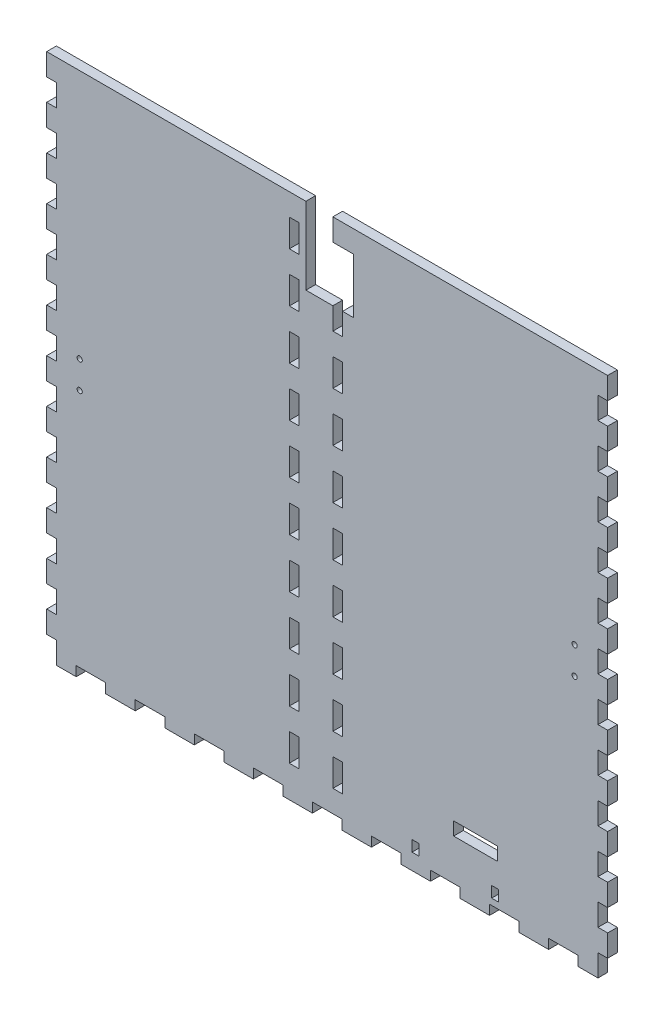
from build123d import *

# Parameters (mm, degrees)
SKETCH1_W                = 323.85
SKETCH1_H                = 139.7
BOSS_EXTRUDE1_DEPTH      = 5.588
SKETCH2_W                = 323.85
SKETCH2_H                = 139.7
SKETCH2_W_2              = 312.674
SKETCH2_H_2              = 128.524
BOSS_EXTRUDE2_DEPTH      = 298.45
SKETCH3_W                = 6.35
SKETCH3_H                = 16.933333333
SKETCH3_H_2              = 16.933333334
DOOR_SLOT_DEPTH          = 12.7
DOOR_GUIDE_HOLES_REACH   = 371.655
SKETCH4_W                = 5.588
SKETCH4_H                = 15.875
LEVER_HOLES_R            = 1.5
LEVER_HOLES_W            = 25.4
LEVER_HOLES_H            = 7.62
LEVER_HOLES_W_2          = 3.999992
LEVER_HOLES_H_2          = 6.35
LEVERHOLE_CUT_DEPTH      = 372.718846804
CUT_EXTRUDE2_REACH       = 451.663
SKETCH7_R                = 26.9875
CUT_EXTRUDE3_REACH       = 451.663
SKETCH8_R                = 3.175
SKETCH15_W               = 152.451001563
SKETCH15_H               = 327.672221774
CUT_EXTRUDE8_DEPTH       = 450.663152197
FRONT_BACK_W             = 5.588
FRONT_BACK_H             = 12.66825
FRONT_BACK_W_2           = 17.044736842
FRONT_BACK_H_2           = 5.588
CUT_EXTRUDE9_DEPTH       = 372.718846804
SKETCH16_W               = 11.938
SKETCH16_H               = 31.75
SKETCH16_W_2             = 15.5800044
SKETCH16_H_2             = 12.7
CUT_EXTRUDE10_DEPTH      = 345.51420408
CUT_EXTRUDE10_DEPTH_BACK = 345.51420408


with BuildPart() as part:
    # Sketch1 → Boss-Extrude1 (new body)
    with BuildSketch(Plane(origin=(0, 0, 0), x_dir=(1, 0, 0), z_dir=(0, 1, 0))):
        Rectangle(SKETCH1_W, SKETCH1_H)
    extrude(amount=BOSS_EXTRUDE1_DEPTH)

    # Sketch2 → Boss-Extrude2 (add)
    with BuildSketch(Plane(origin=(0, 5.588, 0), x_dir=(1, 0, 0), z_dir=(0, 1, 0))):
        Rectangle(SKETCH2_W, SKETCH2_H)
        Rectangle(SKETCH2_W_2, SKETCH2_H_2, mode=Mode.SUBTRACT)
    extrude(amount=BOSS_EXTRUDE2_DEPTH)

    # Sketch3 → Door Slot (cut)
    with BuildSketch(Plane.XY.offset(69.85)):
        with BuildLine():
            Line((-3.302, 282.448), (-3.302, 5.588))
            Line((-3.302, 5.588), (3.302, 5.588))
            Line((3.302, 5.588), (3.302, 291.592))
            Line((3.302, 291.592), (-16.256, 291.592))
            Line((-16.256, 291.592), (-16.256, 284.988))
            Line((-16.256, 284.988), (-5.842, 284.988))
            ThreePointArc((-5.842, 284.988), (-4.045948776, 284.244051224), (-3.302, 282.448))
        make_face()
        with Locations((12.827, 80.433333334)):
            Rectangle(SKETCH3_W, SKETCH3_H)
        with Locations((12.827, 50.8)):
            Rectangle(SKETCH3_W, SKETCH3_H_2)
        with Locations((12.827, 21.166666667)):
            Rectangle(SKETCH3_W, SKETCH3_H)
    extrude(amount=-DOOR_SLOT_DEPTH, mode=Mode.SUBTRACT)

    # Sketch4 → Door Guide Holes (cut, up to next)
    with BuildSketch(Plane.XY.offset(-64.262), mode=Mode.PRIVATE) as door_guide_holes_sk1:
        with Locations((-19.05, 283.4005)):
            Rectangle(SKETCH4_W, SKETCH4_H)
    door_guide_holes_tool1 = extrude(door_guide_holes_sk1.sketch, amount=-DOOR_GUIDE_HOLES_REACH, mode=Mode.PRIVATE) & part.part
    # Sketch4 → Door Guide Holes (cut, up to next)
    with BuildSketch(Plane.XY.offset(-64.262), mode=Mode.PRIVATE) as door_guide_holes_sk2:
        with Locations((-19.05, 254.8255)):
            Rectangle(SKETCH4_W, SKETCH4_H)
    door_guide_holes_tool2 = extrude(door_guide_holes_sk2.sketch, amount=-DOOR_GUIDE_HOLES_REACH, mode=Mode.PRIVATE) & part.part
    # Sketch4 → Door Guide Holes (cut, up to next)
    with BuildSketch(Plane.XY.offset(-64.262), mode=Mode.PRIVATE) as door_guide_holes_sk3:
        with Locations((-19.05, 226.2505)):
            Rectangle(SKETCH4_W, SKETCH4_H)
    door_guide_holes_tool3 = extrude(door_guide_holes_sk3.sketch, amount=-DOOR_GUIDE_HOLES_REACH, mode=Mode.PRIVATE) & part.part
    # Sketch4 → Door Guide Holes (cut, up to next)
    with BuildSketch(Plane.XY.offset(-64.262), mode=Mode.PRIVATE) as door_guide_holes_sk4:
        with Locations((-19.05, 197.6755)):
            Rectangle(SKETCH4_W, SKETCH4_H)
    door_guide_holes_tool4 = extrude(door_guide_holes_sk4.sketch, amount=-DOOR_GUIDE_HOLES_REACH, mode=Mode.PRIVATE) & part.part
    # Sketch4 → Door Guide Holes (cut, up to next)
    with BuildSketch(Plane.XY.offset(-64.262), mode=Mode.PRIVATE) as door_guide_holes_sk5:
        with Locations((-19.05, 169.1005)):
            Rectangle(SKETCH4_W, SKETCH4_H)
    door_guide_holes_tool5 = extrude(door_guide_holes_sk5.sketch, amount=-DOOR_GUIDE_HOLES_REACH, mode=Mode.PRIVATE) & part.part
    # Sketch4 → Door Guide Holes (cut, up to next)
    with BuildSketch(Plane.XY.offset(-64.262), mode=Mode.PRIVATE) as door_guide_holes_sk6:
        with Locations((-19.05, 140.5255)):
            Rectangle(SKETCH4_W, SKETCH4_H)
    door_guide_holes_tool6 = extrude(door_guide_holes_sk6.sketch, amount=-DOOR_GUIDE_HOLES_REACH, mode=Mode.PRIVATE) & part.part
    # Sketch4 → Door Guide Holes (cut, up to next)
    with BuildSketch(Plane.XY.offset(-64.262), mode=Mode.PRIVATE) as door_guide_holes_sk7:
        with Locations((-19.05, 111.9505)):
            Rectangle(SKETCH4_W, SKETCH4_H)
    door_guide_holes_tool7 = extrude(door_guide_holes_sk7.sketch, amount=-DOOR_GUIDE_HOLES_REACH, mode=Mode.PRIVATE) & part.part
    # Sketch4 → Door Guide Holes (cut, up to next)
    with BuildSketch(Plane.XY.offset(-64.262), mode=Mode.PRIVATE) as door_guide_holes_sk8:
        with Locations((-19.05, 83.3755)):
            Rectangle(SKETCH4_W, SKETCH4_H)
    door_guide_holes_tool8 = extrude(door_guide_holes_sk8.sketch, amount=-DOOR_GUIDE_HOLES_REACH, mode=Mode.PRIVATE) & part.part
    # Sketch4 → Door Guide Holes (cut, up to next)
    with BuildSketch(Plane.XY.offset(-64.262), mode=Mode.PRIVATE) as door_guide_holes_sk9:
        with Locations((-19.05, 54.8005)):
            Rectangle(SKETCH4_W, SKETCH4_H)
    door_guide_holes_tool9 = extrude(door_guide_holes_sk9.sketch, amount=-DOOR_GUIDE_HOLES_REACH, mode=Mode.PRIVATE) & part.part
    # Sketch4 → Door Guide Holes (cut, up to next)
    with BuildSketch(Plane.XY.offset(-64.262), mode=Mode.PRIVATE) as door_guide_holes_sk10:
        with Locations((-19.05, 26.2255)):
            Rectangle(SKETCH4_W, SKETCH4_H)
    door_guide_holes_tool10 = extrude(door_guide_holes_sk10.sketch, amount=-DOOR_GUIDE_HOLES_REACH, mode=Mode.PRIVATE) & part.part
    door_guide_holes_1 = door_guide_holes_tool1.solids().sort_by_distance((-19.05, 283.4005, -64.262))[0]
    add(door_guide_holes_1, mode=Mode.SUBTRACT)
    door_guide_holes_2 = door_guide_holes_tool2.solids().sort_by_distance((-19.05, 254.8255, -64.262))[0]
    add(door_guide_holes_2, mode=Mode.SUBTRACT)
    door_guide_holes_3 = door_guide_holes_tool3.solids().sort_by_distance((-19.05, 226.2505, -64.262))[0]
    add(door_guide_holes_3, mode=Mode.SUBTRACT)
    door_guide_holes_4 = door_guide_holes_tool4.solids().sort_by_distance((-19.05, 197.6755, -64.262))[0]
    add(door_guide_holes_4, mode=Mode.SUBTRACT)
    door_guide_holes_5 = door_guide_holes_tool5.solids().sort_by_distance((-19.05, 169.1005, -64.262))[0]
    add(door_guide_holes_5, mode=Mode.SUBTRACT)
    door_guide_holes_6 = door_guide_holes_tool6.solids().sort_by_distance((-19.05, 140.5255, -64.262))[0]
    add(door_guide_holes_6, mode=Mode.SUBTRACT)
    door_guide_holes_7 = door_guide_holes_tool7.solids().sort_by_distance((-19.05, 111.9505, -64.262))[0]
    add(door_guide_holes_7, mode=Mode.SUBTRACT)
    door_guide_holes_8 = door_guide_holes_tool8.solids().sort_by_distance((-19.05, 83.3755, -64.262))[0]
    add(door_guide_holes_8, mode=Mode.SUBTRACT)
    door_guide_holes_9 = door_guide_holes_tool9.solids().sort_by_distance((-19.05, 54.8005, -64.262))[0]
    add(door_guide_holes_9, mode=Mode.SUBTRACT)
    door_guide_holes_10 = door_guide_holes_tool10.solids().sort_by_distance((-19.05, 26.2255, -64.262))[0]
    add(door_guide_holes_10, mode=Mode.SUBTRACT)
    door_guide_holes = door_guide_holes_1 + door_guide_holes_2 + door_guide_holes_3 + door_guide_holes_4 + door_guide_holes_5 + door_guide_holes_6 + door_guide_holes_7 + door_guide_holes_8 + door_guide_holes_9 + door_guide_holes_10  # Door Guide Holes as one shape, for the pattern or mirror that repeats it

    # Mirror1: Door Guide Holes across plane
    add(door_guide_holes.mirror(Plane.ZY.offset(6.477)), mode=Mode.SUBTRACT)

    # Lever Holes → LeverHole Cut (cut, through all)
    with BuildSketch(Plane.XY.offset(69.85)):
        with Locations((-142.875, 159.894)):
            Circle(LEVER_HOLES_R)
        with Locations((-142.875, 144.144)):
            Circle(LEVER_HOLES_R)
        with Locations(Location((142.875, 144.144, 0), (0, 0, 180))):
            Circle(LEVER_HOLES_R)
        with Locations(Location((142.875, 159.894, 0), (0, 0, 180))):
            Circle(LEVER_HOLES_R)
        with Locations((85.725, 33.1129894)):
            Rectangle(LEVER_HOLES_W, LEVER_HOLES_H)
        with Locations((50.975012, 12.413)):
            Rectangle(LEVER_HOLES_W_2, LEVER_HOLES_H_2)
        with Locations((96.975004, 12.413)):
            Rectangle(LEVER_HOLES_W_2, LEVER_HOLES_H_2)
    extrude(amount=-LEVERHOLE_CUT_DEPTH, mode=Mode.SUBTRACT)

    # Sketch7 → Cut-Extrude2 (cut, up to next)
    with BuildSketch(Plane(origin=(161.925, 0, 0), x_dir=(0, 0, -1), z_dir=(1, 0, 0)), mode=Mode.PRIVATE) as cut_extrude2_sk1:
        with Locations((0, 55.372)):
            Circle(SKETCH7_R)
    cut_extrude2_tool1 = extrude(cut_extrude2_sk1.sketch, amount=-CUT_EXTRUDE2_REACH, mode=Mode.PRIVATE) & part.part
    # Sketch7 → Cut-Extrude2 (cut, up to next)
    with BuildSketch(Plane(origin=(161.925, 0, 0), x_dir=(0, 0, -1), z_dir=(1, 0, 0)), mode=Mode.PRIVATE) as cut_extrude2_sk2:
        with BuildLine():
            Line((-37.211, 89.408), (-37.211, 92.583))
            Line((-37.211, 92.583), (-34.036, 92.583))
            ThreePointArc((-34.036, 92.583), (-39.45606403, 94.82806403), (-37.211, 89.408))
        make_face()
    cut_extrude2_tool2 = extrude(cut_extrude2_sk2.sketch, amount=-CUT_EXTRUDE2_REACH, mode=Mode.PRIVATE) & part.part
    # Sketch7 → Cut-Extrude2 (cut, up to next)
    with BuildSketch(Plane(origin=(161.925, 0, 0), x_dir=(0, 0, -1), z_dir=(1, 0, 0)), mode=Mode.PRIVATE) as cut_extrude2_sk3:
        with BuildLine():
            Line((-34.036, 92.583), (-37.211, 92.583))
            Line((-37.211, 92.583), (-37.211, 89.408))
            ThreePointArc((-37.211, 89.408), (-34.96593597, 90.33793597), (-34.036, 92.583))
        make_face()
    cut_extrude2_tool3 = extrude(cut_extrude2_sk3.sketch, amount=-CUT_EXTRUDE2_REACH, mode=Mode.PRIVATE) & part.part
    # Sketch7 → Cut-Extrude2 (cut, up to next)
    with BuildSketch(Plane(origin=(161.925, 0, 0), x_dir=(0, 0, -1), z_dir=(1, 0, 0)), mode=Mode.PRIVATE) as cut_extrude2_sk4:
        with BuildLine():
            Line((-37.211, 89.408), (-37.211, 92.583))
            Line((-37.211, 92.583), (-34.036, 92.583))
            ThreePointArc((-34.036, 92.583), (-39.45606403, 94.82806403), (-37.211, 89.408))
        make_face()
    cut_extrude2_tool4 = extrude(cut_extrude2_sk4.sketch, amount=-CUT_EXTRUDE2_REACH, mode=Mode.PRIVATE) & part.part
    # Sketch7 → Cut-Extrude2 (cut, up to next)
    with BuildSketch(Plane(origin=(161.925, 0, 0), x_dir=(0, 0, -1), z_dir=(1, 0, 0)), mode=Mode.PRIVATE) as cut_extrude2_sk5:
        with BuildLine():
            Line((-34.036, 92.583), (-37.211, 92.583))
            Line((-37.211, 92.583), (-37.211, 89.408))
            ThreePointArc((-37.211, 89.408), (-34.96593597, 90.33793597), (-34.036, 92.583))
        make_face()
    cut_extrude2_tool5 = extrude(cut_extrude2_sk5.sketch, amount=-CUT_EXTRUDE2_REACH, mode=Mode.PRIVATE) & part.part
    # Sketch7 → Cut-Extrude2 (cut, up to next)
    with BuildSketch(Plane(origin=(161.925, 0, 0), x_dir=(0, 0, -1), z_dir=(1, 0, 0)), mode=Mode.PRIVATE) as cut_extrude2_sk6:
        with BuildLine():
            ThreePointArc((40.386, 92.583), (37.211, 95.758), (34.036, 92.583))
            Line((34.036, 92.583), (37.211, 92.583))
            Line((37.211, 92.583), (37.211, 89.408))
            ThreePointArc((37.211, 89.408), (39.45606403, 90.33793597), (40.386, 92.583))
        make_face()
    cut_extrude2_tool6 = extrude(cut_extrude2_sk6.sketch, amount=-CUT_EXTRUDE2_REACH, mode=Mode.PRIVATE) & part.part
    # Sketch7 → Cut-Extrude2 (cut, up to next)
    with BuildSketch(Plane(origin=(161.925, 0, 0), x_dir=(0, 0, -1), z_dir=(1, 0, 0)), mode=Mode.PRIVATE) as cut_extrude2_sk7:
        with BuildLine():
            Line((37.211, 92.583), (34.036, 92.583))
            ThreePointArc((34.036, 92.583), (34.96593597, 90.33793597), (37.211, 89.408))
            Line((37.211, 89.408), (37.211, 92.583))
        make_face()
    cut_extrude2_tool7 = extrude(cut_extrude2_sk7.sketch, amount=-CUT_EXTRUDE2_REACH, mode=Mode.PRIVATE) & part.part
    # Sketch7 → Cut-Extrude2 (cut, up to next)
    with BuildSketch(Plane(origin=(161.925, 0, 0), x_dir=(0, 0, -1), z_dir=(1, 0, 0)), mode=Mode.PRIVATE) as cut_extrude2_sk8:
        with BuildLine():
            ThreePointArc((40.386, 92.583), (37.211, 95.758), (34.036, 92.583))
            Line((34.036, 92.583), (37.211, 92.583))
            Line((37.211, 92.583), (37.211, 89.408))
            ThreePointArc((37.211, 89.408), (39.45606403, 90.33793597), (40.386, 92.583))
        make_face()
    cut_extrude2_tool8 = extrude(cut_extrude2_sk8.sketch, amount=-CUT_EXTRUDE2_REACH, mode=Mode.PRIVATE) & part.part
    # Sketch7 → Cut-Extrude2 (cut, up to next)
    with BuildSketch(Plane(origin=(161.925, 0, 0), x_dir=(0, 0, -1), z_dir=(1, 0, 0)), mode=Mode.PRIVATE) as cut_extrude2_sk9:
        with BuildLine():
            Line((37.211, 92.583), (34.036, 92.583))
            ThreePointArc((34.036, 92.583), (34.96593597, 90.33793597), (37.211, 89.408))
            Line((37.211, 89.408), (37.211, 92.583))
        make_face()
    cut_extrude2_tool9 = extrude(cut_extrude2_sk9.sketch, amount=-CUT_EXTRUDE2_REACH, mode=Mode.PRIVATE) & part.part
    # Sketch7 → Cut-Extrude2 (cut, up to next)
    with BuildSketch(Plane(origin=(161.925, 0, 0), x_dir=(0, 0, -1), z_dir=(1, 0, 0)), mode=Mode.PRIVATE) as cut_extrude2_sk10:
        with BuildLine():
            ThreePointArc((-34.036, 18.161), (-34.96593597, 20.40606403), (-37.211, 21.336))
            Line((-37.211, 21.336), (-37.211, 18.161))
            Line((-37.211, 18.161), (-34.036, 18.161))
        make_face()
    cut_extrude2_tool10 = extrude(cut_extrude2_sk10.sketch, amount=-CUT_EXTRUDE2_REACH, mode=Mode.PRIVATE) & part.part
    # Sketch7 → Cut-Extrude2 (cut, up to next)
    with BuildSketch(Plane(origin=(161.925, 0, 0), x_dir=(0, 0, -1), z_dir=(1, 0, 0)), mode=Mode.PRIVATE) as cut_extrude2_sk11:
        with BuildLine():
            Line((-37.211, 18.161), (-37.211, 21.336))
            ThreePointArc((-37.211, 21.336), (-39.45606403, 15.91593597), (-34.036, 18.161))
            Line((-34.036, 18.161), (-37.211, 18.161))
        make_face()
    cut_extrude2_tool11 = extrude(cut_extrude2_sk11.sketch, amount=-CUT_EXTRUDE2_REACH, mode=Mode.PRIVATE) & part.part
    # Sketch7 → Cut-Extrude2 (cut, up to next)
    with BuildSketch(Plane(origin=(161.925, 0, 0), x_dir=(0, 0, -1), z_dir=(1, 0, 0)), mode=Mode.PRIVATE) as cut_extrude2_sk12:
        with BuildLine():
            ThreePointArc((-34.036, 18.161), (-34.96593597, 20.40606403), (-37.211, 21.336))
            Line((-37.211, 21.336), (-37.211, 18.161))
            Line((-37.211, 18.161), (-34.036, 18.161))
        make_face()
    cut_extrude2_tool12 = extrude(cut_extrude2_sk12.sketch, amount=-CUT_EXTRUDE2_REACH, mode=Mode.PRIVATE) & part.part
    # Sketch7 → Cut-Extrude2 (cut, up to next)
    with BuildSketch(Plane(origin=(161.925, 0, 0), x_dir=(0, 0, -1), z_dir=(1, 0, 0)), mode=Mode.PRIVATE) as cut_extrude2_sk13:
        with BuildLine():
            Line((-37.211, 18.161), (-37.211, 21.336))
            ThreePointArc((-37.211, 21.336), (-39.45606403, 15.91593597), (-34.036, 18.161))
            Line((-34.036, 18.161), (-37.211, 18.161))
        make_face()
    cut_extrude2_tool13 = extrude(cut_extrude2_sk13.sketch, amount=-CUT_EXTRUDE2_REACH, mode=Mode.PRIVATE) & part.part
    # Sketch7 → Cut-Extrude2 (cut, up to next)
    with BuildSketch(Plane(origin=(161.925, 0, 0), x_dir=(0, 0, -1), z_dir=(1, 0, 0)), mode=Mode.PRIVATE) as cut_extrude2_sk14:
        with BuildLine():
            ThreePointArc((40.386, 18.161), (39.45606403, 20.40606403), (37.211, 21.336))
            Line((37.211, 21.336), (37.211, 18.161))
            Line((37.211, 18.161), (34.036, 18.161))
            ThreePointArc((34.036, 18.161), (37.211, 14.986), (40.386, 18.161))
        make_face()
    cut_extrude2_tool14 = extrude(cut_extrude2_sk14.sketch, amount=-CUT_EXTRUDE2_REACH, mode=Mode.PRIVATE) & part.part
    # Sketch7 → Cut-Extrude2 (cut, up to next)
    with BuildSketch(Plane(origin=(161.925, 0, 0), x_dir=(0, 0, -1), z_dir=(1, 0, 0)), mode=Mode.PRIVATE) as cut_extrude2_sk15:
        with BuildLine():
            Line((37.211, 18.161), (37.211, 21.336))
            ThreePointArc((37.211, 21.336), (34.96593597, 20.40606403), (34.036, 18.161))
            Line((34.036, 18.161), (37.211, 18.161))
        make_face()
    cut_extrude2_tool15 = extrude(cut_extrude2_sk15.sketch, amount=-CUT_EXTRUDE2_REACH, mode=Mode.PRIVATE) & part.part
    # Sketch7 → Cut-Extrude2 (cut, up to next)
    with BuildSketch(Plane(origin=(161.925, 0, 0), x_dir=(0, 0, -1), z_dir=(1, 0, 0)), mode=Mode.PRIVATE) as cut_extrude2_sk16:
        with BuildLine():
            ThreePointArc((40.386, 18.161), (39.45606403, 20.40606403), (37.211, 21.336))
            Line((37.211, 21.336), (37.211, 18.161))
            Line((37.211, 18.161), (34.036, 18.161))
            ThreePointArc((34.036, 18.161), (37.211, 14.986), (40.386, 18.161))
        make_face()
    cut_extrude2_tool16 = extrude(cut_extrude2_sk16.sketch, amount=-CUT_EXTRUDE2_REACH, mode=Mode.PRIVATE) & part.part
    # Sketch7 → Cut-Extrude2 (cut, up to next)
    with BuildSketch(Plane(origin=(161.925, 0, 0), x_dir=(0, 0, -1), z_dir=(1, 0, 0)), mode=Mode.PRIVATE) as cut_extrude2_sk17:
        with BuildLine():
            Line((37.211, 18.161), (37.211, 21.336))
            ThreePointArc((37.211, 21.336), (34.96593597, 20.40606403), (34.036, 18.161))
            Line((34.036, 18.161), (37.211, 18.161))
        make_face()
    cut_extrude2_tool17 = extrude(cut_extrude2_sk17.sketch, amount=-CUT_EXTRUDE2_REACH, mode=Mode.PRIVATE) & part.part
    add(cut_extrude2_tool1.solids().sort_by_distance((161.925, 55.372, 0))[0], mode=Mode.SUBTRACT)
    add(cut_extrude2_tool2.solids().sort_by_distance((161.925, 93.032171, 37.660171))[0], mode=Mode.SUBTRACT)
    add(cut_extrude2_tool3.solids().sort_by_distance((161.925, 91.235488, 35.863488))[0], mode=Mode.SUBTRACT)
    add(cut_extrude2_tool4.solids().sort_by_distance((161.925, 93.032171, 37.660171))[0], mode=Mode.SUBTRACT)
    add(cut_extrude2_tool5.solids().sort_by_distance((161.925, 91.235488, 35.863488))[0], mode=Mode.SUBTRACT)
    add(cut_extrude2_tool6.solids().sort_by_distance((161.925, 93.032171, -37.660171))[0], mode=Mode.SUBTRACT)
    add(cut_extrude2_tool7.solids().sort_by_distance((161.925, 91.235488, -35.863488))[0], mode=Mode.SUBTRACT)
    add(cut_extrude2_tool8.solids().sort_by_distance((161.925, 93.032171, -37.660171))[0], mode=Mode.SUBTRACT)
    add(cut_extrude2_tool9.solids().sort_by_distance((161.925, 91.235488, -35.863488))[0], mode=Mode.SUBTRACT)
    add(cut_extrude2_tool10.solids().sort_by_distance((161.925, 19.508512, 35.863488))[0], mode=Mode.SUBTRACT)
    add(cut_extrude2_tool11.solids().sort_by_distance((161.925, 17.711829, 37.660171))[0], mode=Mode.SUBTRACT)
    add(cut_extrude2_tool12.solids().sort_by_distance((161.925, 19.508512, 35.863488))[0], mode=Mode.SUBTRACT)
    add(cut_extrude2_tool13.solids().sort_by_distance((161.925, 17.711829, 37.660171))[0], mode=Mode.SUBTRACT)
    add(cut_extrude2_tool14.solids().sort_by_distance((161.925, 17.711829, -37.660171))[0], mode=Mode.SUBTRACT)
    add(cut_extrude2_tool15.solids().sort_by_distance((161.925, 19.508512, -35.863488))[0], mode=Mode.SUBTRACT)
    add(cut_extrude2_tool16.solids().sort_by_distance((161.925, 17.711829, -37.660171))[0], mode=Mode.SUBTRACT)
    add(cut_extrude2_tool17.solids().sort_by_distance((161.925, 19.508512, -35.863488))[0], mode=Mode.SUBTRACT)

    # Sketch8 → Cut-Extrude3 (cut, up to next)
    with BuildSketch(Plane.ZY.offset(161.925), mode=Mode.PRIVATE) as cut_extrude3_sk1:
        with Locations((0, 19.05)):
            Circle(SKETCH8_R)
    cut_extrude3_tool1 = extrude(cut_extrude3_sk1.sketch, amount=-CUT_EXTRUDE3_REACH, mode=Mode.PRIVATE) & part.part
    add(cut_extrude3_tool1.solids().sort_by_distance((-161.925, 19.05, 0))[0], mode=Mode.SUBTRACT)

    # Sketch15 → Cut-Extrude8 (cut, through all)
    with BuildSketch(Plane.ZY.offset(161.925)):
        with Locations((11.963500782, 140.201889113)):
            Rectangle(SKETCH15_W, SKETCH15_H)
    extrude(amount=-CUT_EXTRUDE8_DEPTH, mode=Mode.SUBTRACT)

    # Front/Back → Cut-Extrude9 (cut, through all)
    with BuildSketch(Plane.XY.offset(69.85)):
        with Locations((-159.131, 6.334125)):
            Rectangle(FRONT_BACK_W, FRONT_BACK_H)
        with Locations((-136.357894737, 2.794)):
            Rectangle(FRONT_BACK_W_2, FRONT_BACK_H_2)
        with Locations((-159.131, 31.670625)):
            Rectangle(FRONT_BACK_W, FRONT_BACK_H)
        with Locations((-102.268421053, 2.794)):
            Rectangle(FRONT_BACK_W_2, FRONT_BACK_H_2)
        with Locations((-159.131, 57.007125)):
            Rectangle(FRONT_BACK_W, FRONT_BACK_H)
        with Locations((-68.178947368, 2.794)):
            Rectangle(FRONT_BACK_W_2, FRONT_BACK_H_2)
        with Locations((-159.131, 82.343625)):
            Rectangle(FRONT_BACK_W, FRONT_BACK_H)
        with Locations((-34.089473684, 2.794)):
            Rectangle(FRONT_BACK_W_2, FRONT_BACK_H_2)
        with Locations((-159.131, 107.680125)):
            Rectangle(FRONT_BACK_W, FRONT_BACK_H)
        with Locations((0, 2.794)):
            Rectangle(FRONT_BACK_W_2, FRONT_BACK_H_2)
        with Locations((-159.131, 133.016625)):
            Rectangle(FRONT_BACK_W, FRONT_BACK_H)
        with Locations((34.089473684, 2.794)):
            Rectangle(FRONT_BACK_W_2, FRONT_BACK_H_2)
        with Locations((-159.131, 158.353125)):
            Rectangle(FRONT_BACK_W, FRONT_BACK_H)
        with Locations((68.178947368, 2.794)):
            Rectangle(FRONT_BACK_W_2, FRONT_BACK_H_2)
        with Locations((-159.131, 183.689625)):
            Rectangle(FRONT_BACK_W, FRONT_BACK_H)
        with Locations((102.268421053, 2.794)):
            Rectangle(FRONT_BACK_W_2, FRONT_BACK_H_2)
        with Locations((-159.131, 209.026125)):
            Rectangle(FRONT_BACK_W, FRONT_BACK_H)
        with Locations((136.357894737, 2.794)):
            Rectangle(FRONT_BACK_W_2, FRONT_BACK_H_2)
        with Locations((-159.131, 234.362625)):
            Rectangle(FRONT_BACK_W, FRONT_BACK_H)
        with Locations((159.131, 6.334125)):
            Rectangle(FRONT_BACK_W, FRONT_BACK_H)
        with Locations((-159.131, 259.699125)):
            Rectangle(FRONT_BACK_W, FRONT_BACK_H)
        with Locations((159.131, 31.670625)):
            Rectangle(FRONT_BACK_W, FRONT_BACK_H)
        with Locations((-159.131, 285.035625)):
            Rectangle(FRONT_BACK_W, FRONT_BACK_H)
        with Locations((159.131, 57.007125)):
            Rectangle(FRONT_BACK_W, FRONT_BACK_H)
        with Locations((159.131, 82.343625)):
            Rectangle(FRONT_BACK_W, FRONT_BACK_H)
        with Locations((159.131, 107.680125)):
            Rectangle(FRONT_BACK_W, FRONT_BACK_H)
        with Locations((159.131, 133.016625)):
            Rectangle(FRONT_BACK_W, FRONT_BACK_H)
        with Locations((159.131, 158.353125)):
            Rectangle(FRONT_BACK_W, FRONT_BACK_H)
        with Locations((159.131, 183.689625)):
            Rectangle(FRONT_BACK_W, FRONT_BACK_H)
        with Locations((159.131, 209.026125)):
            Rectangle(FRONT_BACK_W, FRONT_BACK_H)
        with Locations((159.131, 234.362625)):
            Rectangle(FRONT_BACK_W, FRONT_BACK_H)
        with Locations((159.131, 259.699125)):
            Rectangle(FRONT_BACK_W, FRONT_BACK_H)
        with Locations((159.131, 285.035625)):
            Rectangle(FRONT_BACK_W, FRONT_BACK_H)
    extrude(amount=-CUT_EXTRUDE9_DEPTH, mode=Mode.SUBTRACT)

    # Sketch16 → Cut-Extrude10 (cut, two sides)
    with BuildSketch(Plane(origin=(0, 0, -69.85), x_dir=(-1, 0, 0), z_dir=(0, 0, -1))) as cut_extrude10_sk:
        with Locations((-9.271, 275.463)):
            Rectangle(SKETCH16_W, SKETCH16_H)
        with Locations((4.4880022, 275.463)):
            Rectangle(SKETCH16_W_2, SKETCH16_H)
        with Locations((4.4880022, 297.688)):
            Rectangle(SKETCH16_W_2, SKETCH16_H_2)
    extrude(amount=CUT_EXTRUDE10_DEPTH, mode=Mode.SUBTRACT)
    extrude(cut_extrude10_sk.sketch, amount=-CUT_EXTRUDE10_DEPTH_BACK, mode=Mode.SUBTRACT)


solid = part.part
